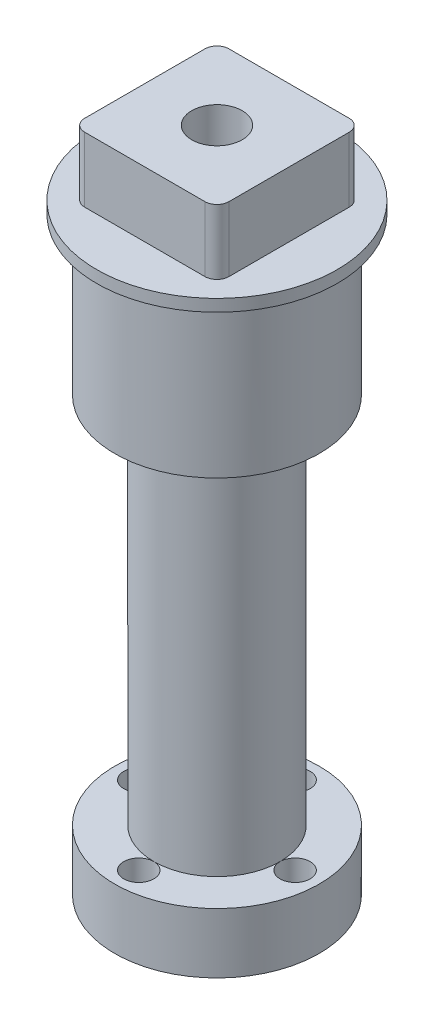
from build123d import *

# Parameters (mm, degrees)
CUT_EXTRUDE_START   = -50
SKETCH_2_R          = 1.25
CUT_EXTRUDE_2_DEPTH = 6
SKETCH_4_W          = 12
SKETCH_4_H          = 12
EXTRUDE_1_DEPTH     = 5.4
FILLET_1_R          = 1
SKETCH_5_W          = 1.5
SKETCH_5_H          = 1
SKETCH_6_R          = 4.25
EXTRUDE_2_DEPTH     = 6
HOLE_WIZARD_M5_2_D  = 4.2


with BuildPart() as part:
    # 草图1 → 旋转1 (revolve)
    with BuildSketch(Plane.XY):
        Polygon((-8.5, 36), (-5.25, 36), (-5.25, 5), (-8.5, 5), (-8.5, 0), (-4.25, 0), (-4.25, 50), (-8.5, 50), align=None)
    revolve(axis=Axis((0, 0, 0), (0, 1, 0)))

    # 草图2 → 切除-拉伸2 (cut)
    with BuildSketch(Plane(origin=(0, 50, 0), x_dir=(1, 0, 0), z_dir=(0, 1, 0)).offset(CUT_EXTRUDE_START)):
        with Locations((0, 6.5)):
            Circle(SKETCH_2_R)
        with Locations((0, -6.5)):
            Circle(SKETCH_2_R)
        with Locations((-6.5, 0)):
            Circle(SKETCH_2_R)
        with Locations((6.5, 0)):
            Circle(SKETCH_2_R)
    extrude(amount=CUT_EXTRUDE_2_DEPTH, mode=Mode.SUBTRACT)

    # 草图4 → 凸台-拉伸1 (add)
    with BuildSketch(Plane(origin=(0, 50, 0), x_dir=(1, 0, 0), z_dir=(0, 1, 0))):
        Rectangle(SKETCH_4_W, SKETCH_4_H)
    extrude(amount=EXTRUDE_1_DEPTH)

    # 圆角1
    fillet_1_edges = [part.edges().sort_by_distance(p)[0] for p in [
        (6, 52.7, 6),
        (6, 52.7, -6),
        (-6, 52.7, -6),
        (-6, 52.7, 6),
    ]]
    fillet(fillet_1_edges, radius=FILLET_1_R)

    # 草图5 → 旋转2 (revolve)
    with BuildSketch(Plane.XY):
        with Locations((-9.25, 49.5)):
            Rectangle(SKETCH_5_W, SKETCH_5_H)
    revolve(axis=Axis((0, 0, 0), (0, 1, 0)))

    # 草图6 → 凸台-拉伸2 (add)
    with BuildSketch(Plane.XZ.offset(-50)):
        Circle(SKETCH_6_R)
    extrude(amount=EXTRUDE_2_DEPTH)

    # M5 螺纹孔2 (through all)
    with Locations(Plane(origin=(0, 55.4, 0), x_dir=(1, 0, 0), z_dir=(0, 1, 0))):
        with Locations((0, 0)):
            Hole(HOLE_WIZARD_M5_2_D / 2)


solid = part.part
